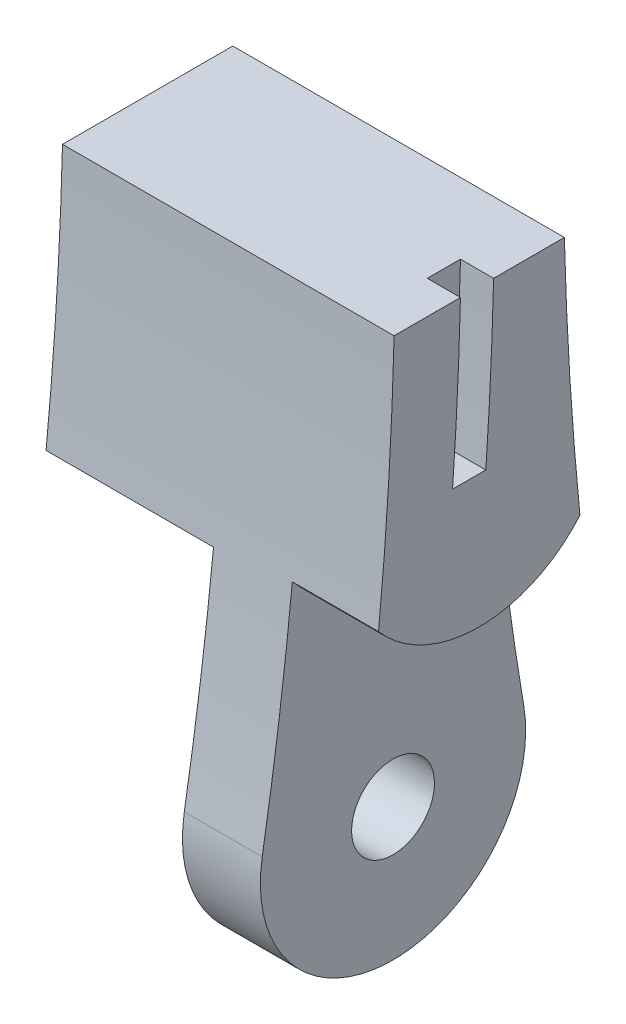
from build123d import *

# Parameters (mm, degrees)
SKETCH1_R                = 1.5
SKETCH1_R_2              = 2.5
BOSS_EXTRUDE1_DEPTH      = 20
SKETCH2_W                = 8.1
SKETCH2_H                = 20
SKETCH2_W_2              = 5.2
SKETCH2_W_3              = 5.1
CUT_EXTRUDE1_DEPTH       = 20
CUT_EXTRUDE1_DEPTH_BACK  = 20
CUT_EXTRUDE2_DEPTH       = 9
BOSS_EXTRUDE2_DEPTH      = 11.9
SKETCH5_R                = 3
BOSS_EXTRUDE3_DEPTH      = 5
CUT_EXTRUDE6_DEPTH       = 1
SKETCH13_R               = 2.5
CUT_EXTRUDE7_DEPTH       = 4
BOSS_EXTRUDE4_DEPTH      = 3
CUT_EXTRUDE9_DEPTH       = 3
SKETCH17_W               = 9
SKETCH17_H               = 3.569322199
CUT_EXTRUDE11_DEPTH      = 3
SKETCH18_W               = 5.770974844
SKETCH18_H               = 0.772936936
BOSS_EXTRUDE5_DEPTH      = 6.9
BOSS_EXTRUDE5_DEPTH_BACK = 1
SKETCH19_W               = 5.1
SKETCH19_H               = 16.397725614
CUT_EXTRUDE12_DEPTH      = 0.301495
SKETCH20_W               = 5
SKETCH20_H               = 12.419235667
CUT_EXTRUDE13_DEPTH      = 10
BOSS_EXTRUDE6_DEPTH      = 2
SKETCH23_W               = 4.9
SKETCH23_H               = 6
BOSS_EXTRUDE7_DEPTH      = 4
SKETCH22_R               = 1
CUT_EXTRUDE15_DEPTH      = 8
BOSS_EXTRUDE8_DEPTH      = 2
SKETCH14_R               = 1.5
CUT_EXTRUDE8_DEPTH       = 10.1
CUT_EXTRUDE17_DEPTH      = 8.1
CUT_EXTRUDE17_DEPTH_BACK = 2
CUT_EXTRUDE18_DEPTH      = 2
CUT_EXTRUDE20_DEPTH      = 5.2
SKETCH30_W               = 6.9
SKETCH30_H               = 20
CUT_EXTRUDE21_DEPTH      = 0.283797
CUT_EXTRUDE22_REACH      = 91.699
SKETCH31_W               = 2
SKETCH31_H               = 11.022421386
CUT_EXTRUDE23_DEPTH      = 7
CUT_EXTRUDE24_DEPTH      = 21
SKETCH34_W               = 70.65252795
SKETCH34_H               = 74.33474439
CUT_EXTRUDE25_DEPTH      = 21


with BuildPart() as part:
    # Sketch1 → Boss-Extrude1 (new body)
    with BuildSketch(Plane(origin=(0, 0, 0), x_dir=(0, 0, -1), z_dir=(1, 0, 0))):
        with BuildLine():
            ThreePointArc((9.765353557, 20.116545894), (0, 32.270117322), (-9.765353557, 20.116545894))
            ThreePointArc((-9.765353557, 20.116545894), (-5.132645827, -18.047253777), (-7.88740095, -56.392382678))
            ThreePointArc((-7.88740095, -56.392382678), (0, -65.729882678), (7.88740095, -56.392382678))
            ThreePointArc((7.88740095, -56.392382678), (5.132645827, -18.047253777), (9.765353557, 20.116545894))
        make_face()
        with Locations((0, 22.270117322)):
            Circle(SKETCH1_R, mode=Mode.SUBTRACT)
        with Locations((0, -57.729882678)):
            Circle(SKETCH1_R_2, mode=Mode.SUBTRACT)
    extrude(amount=BOSS_EXTRUDE1_DEPTH)

    # Sketch2 → Cut-Extrude1 (cut, two sides)
    with BuildSketch(Plane.XY) as cut_extrude1_sk:
        with Locations((4.05, -55.729882678)):
            Rectangle(SKETCH2_W, SKETCH2_H)
        with Locations((17.4, -55.729882678)):
            Rectangle(SKETCH2_W_2, SKETCH2_H)
        with Locations((5.55, 22.270117322)):
            Rectangle(SKETCH2_W_3, SKETCH2_H)
    extrude(amount=CUT_EXTRUDE1_DEPTH, mode=Mode.SUBTRACT)
    extrude(cut_extrude1_sk.sketch, amount=-CUT_EXTRUDE1_DEPTH_BACK, mode=Mode.SUBTRACT)

    # Sketch3 → Cut-Extrude2 (cut)
    with BuildSketch(Plane.ZY.offset(-8.1)):
        with BuildLine():
            Line((8.5, 22.270117322), (8.5, 40.909533312))
            Line((8.5, 40.909533312), (-17.52872033, 40.909533312))
            Line((-17.52872033, 40.909533312), (-17.52872033, 13.770117322))
            Line((-17.52872033, 13.770117322), (0, 13.770117322))
            ThreePointArc((0, 13.770117322), (6.01040764, 16.259709682), (8.5, 22.270117322))
        make_face()
    extrude(amount=-CUT_EXTRUDE2_DEPTH, mode=Mode.SUBTRACT)

    # Sketch4 → Boss-Extrude2 (add, through all)
    with BuildSketch(Plane.ZY.offset(-8.1)):
        Polygon((8.5, 27.537944199), (8.283796844, 12.741558936), (10.283796844, 12.741558936), (10.283796844, 27.537944199), align=None)
    extrude(amount=-BOSS_EXTRUDE2_DEPTH)

    # Sketch5 → Boss-Extrude3 (add)
    with BuildSketch(Plane.ZY.offset(-8.1)):
        with BuildLine():
            Line((8.145156861, 11.968622), (8.447845456, 23.968622))
            Line((8.447845456, 23.968622), (9.854698466, 23.968622))
            Line((9.854698466, 23.968622), (15.022421386, 23.968622))
            ThreePointArc((15.022421386, 23.968622), (21.022421386, 17.968622), (15.022421386, 11.968622))
            Line((15.022421386, 11.968622), (8.145156861, 11.968622))
        make_face()
        with Locations((15.022421386, 17.968622)):
            Circle(SKETCH5_R, mode=Mode.SUBTRACT)
    extrude(amount=-BOSS_EXTRUDE3_DEPTH)

    # Sketch12 → Cut-Extrude6 (cut)
    with BuildSketch(Plane(origin=(13.1, 0, 0), x_dir=(0, 0, -1), z_dir=(1, 0, 0))):
        Polygon((-13.902900694, 14.968622), (-13.902900694, 12.968622), (-15.902900694, 12.968622), (-15.902900694, 14.968622), (-15.902900694, 15.294296094), (-13.902900694, 15.294296094), align=None)
    extrude(amount=-CUT_EXTRUDE6_DEPTH, mode=Mode.SUBTRACT)

    # Sketch13 → Cut-Extrude7 (cut)
    with BuildSketch(Plane.ZY.offset(-17.1)):
        with Locations((0, 22.270117322)):
            Circle(SKETCH13_R)
    extrude(amount=-CUT_EXTRUDE7_DEPTH, mode=Mode.SUBTRACT)

    # Sketch15 → Boss-Extrude4 (add)
    with BuildSketch(Plane.ZY):
        Polygon((10, 22.270117322), (10, 11.968622), (8.145156861, 11.968622), (7.595672539, 11.968622), align=None)
    extrude(amount=-BOSS_EXTRUDE4_DEPTH)

    # Sketch16 → Cut-Extrude9 (cut)
    with BuildSketch(Plane(origin=(20, 0, 0), x_dir=(0, 0, -1), z_dir=(1, 0, 0))):
        with BuildLine():
            Line((-10.283796844, 23.968622), (-9.854698466, 23.968622))
            ThreePointArc((-9.854698466, 23.968622), (-9.349264901, 25.818531871), (-8.5, 27.537944199))
            Line((-8.5, 27.537944199), (-10.283796844, 27.537944199))
            Line((-10.283796844, 27.537944199), (-10.283796844, 23.968622))
        make_face()
    extrude(amount=-CUT_EXTRUDE9_DEPTH, mode=Mode.SUBTRACT)

    # Sketch17 → Cut-Extrude11 (cut)
    with BuildSketch(Plane.XY.offset(10.283796844)):
        with Locations((12.6, 25.7532831)):
            Rectangle(SKETCH17_W, SKETCH17_H)
    extrude(amount=-CUT_EXTRUDE11_DEPTH, mode=Mode.SUBTRACT)

    # Sketch18 → Boss-Extrude5 (add, two sides)
    with BuildSketch(Plane(origin=(13.1, 0, 0), x_dir=(0, 0, -1), z_dir=(1, 0, 0))) as boss_extrude5_sk:
        with Locations((-7.398309422, 12.355090468)):
            Rectangle(SKETCH18_W, SKETCH18_H)
    extrude(amount=BOSS_EXTRUDE5_DEPTH)
    extrude(boss_extrude5_sk.sketch, amount=-BOSS_EXTRUDE5_DEPTH_BACK)

    # Sketch19 → Cut-Extrude12 (cut)
    with BuildSketch(Plane(origin=(0, 12.270117322, 0), x_dir=(1, 0, 0), z_dir=(0, 1, 0))):
        with Locations((5.55, 0)):
            Rectangle(SKETCH19_W, SKETCH19_H)
    extrude(amount=-CUT_EXTRUDE12_DEPTH, mode=Mode.SUBTRACT)

    # Sketch20 → Cut-Extrude13 (cut)
    with BuildSketch(Plane.ZY.offset(-17.1)):
        with Locations((0, 28.479735156)):
            Rectangle(SKETCH20_W, SKETCH20_H)
    extrude(amount=-CUT_EXTRUDE13_DEPTH, mode=Mode.SUBTRACT)

    # Sketch21 → Boss-Extrude6 (add)
    with BuildSketch(Plane.ZY.offset(-17.1)):
        with BuildLine():
            Line((-8.473151119, 13.770117322), (0.278481736, 12.273995678))
            ThreePointArc((0.278481736, 12.273995678), (9.936881703, 21.148341047), (2.5, 31.952575688))
            Line((2.5, 31.952575688), (2.5, 22.270117322))
            ThreePointArc((2.5, 22.270117322), (0, 19.770117322), (-2.5, 22.270117322))
            Line((-2.5, 22.270117322), (-2.5, 31.952575688))
            ThreePointArc((-2.5, 31.952575688), (-8.522477621, 27.501501002), (-9.765353557, 20.116545894))
            ThreePointArc((-9.765353557, 20.116545894), (-9.093560923, 16.948562662), (-8.473151119, 13.770117322))
        make_face()
    extrude(amount=BOSS_EXTRUDE6_DEPTH)

    # Sketch23 → Boss-Extrude7 (add)
    with BuildSketch(Plane.XY.offset(10.283796844)):
        with Locations((17.55, 26.968622)):
            Rectangle(SKETCH23_W, SKETCH23_H)
    extrude(amount=-BOSS_EXTRUDE7_DEPTH)

    # Sketch22 → Cut-Extrude15 (cut)
    with BuildSketch(Plane.XY.offset(10.283796844)):
        with Locations((17.55, 26.870117322)):
            Circle(SKETCH22_R)
    extrude(amount=-CUT_EXTRUDE15_DEPTH, mode=Mode.SUBTRACT)

    # Sketch24 → Boss-Extrude8 (add)
    with BuildSketch(Plane.ZY.offset(-8.1)):
        with BuildLine():
            Line((5.147845456, 19.737443909), (5.147845456, 15.506265819))
            Line((5.147845456, 15.506265819), (8.447845456, 15.506265819))
            Line((8.447845456, 15.506265819), (8.447845456, 23.968622))
            add(Edge.make_bspline(
                [(8.447845456, 23.968622), (5.147845456, 23.968622), (5.147845456, 19.737443909)],
                knots=[3.141592654, 3.141592654, 3.141592654, 4.71238898, 4.71238898, 4.71238898], degree=2, weights=[1, 0.707106781, 1]))
        make_face()
    extrude(amount=-BOSS_EXTRUDE8_DEPTH)

    # Sketch14 → Cut-Extrude8 (cut)
    with BuildSketch(Plane.ZY):
        with Locations((7.532575614, 18.331804915)):
            Circle(SKETCH14_R)
    extrude(amount=-CUT_EXTRUDE8_DEPTH, mode=Mode.SUBTRACT)

    # Sketch25 → Cut-Extrude17 (cut, two sides)
    with BuildSketch(Plane.ZY.offset(-8.1)) as cut_extrude17_sk:
        with BuildLine():
            Line((12, -45.729882678), (8.346153846, -36.960651908))
            ThreePointArc((8.346153846, -36.960651908), (6.973852263, -42.37911752), (2.5, -45.729882678))
            Line((2.5, -45.729882678), (2.5, -53.227383372))
            ThreePointArc((2.5, -53.227383372), (0, -62.879882678), (-2.5, -53.227383372))
            Line((-2.5, -53.227383372), (-2.5, -45.729882678))
            ThreePointArc((-2.5, -45.729882678), (-6.973852263, -42.37911752), (-8.346153846, -36.960651908))
            Line((-8.346153846, -36.960651908), (-12, -45.729882678))
            Line((-12, -45.729882678), (-12, -57.729882678))
            ThreePointArc((-12, -57.729882678), (0, -69.729882678), (12, -57.729882678))
            Line((12, -57.729882678), (12, -45.729882678))
        make_face()
    extrude(amount=CUT_EXTRUDE17_DEPTH, mode=Mode.SUBTRACT)
    extrude(cut_extrude17_sk.sketch, amount=-CUT_EXTRUDE17_DEPTH_BACK, mode=Mode.SUBTRACT)

    # Sketch26 → Cut-Extrude18 (cut)
    with BuildSketch(Plane(origin=(20, 0, 0), x_dir=(0, 0, -1), z_dir=(1, 0, 0))):
        with BuildLine():
            Line((-7.209968303, 15.085404497), (-10.283796844, 15.085404497))
            Line((-10.283796844, 15.085404497), (-10.283796844, 17.085404497))
            Line((-10.283796844, 17.085404497), (-7.209968303, 17.085404497))
            ThreePointArc((-7.209968303, 17.085404497), (-4.010444351, 15.949526558), (-2.243391617, 13.050441039))
            ThreePointArc((-2.243391617, 13.050441039), (0.649659998, -12.257973546), (0.397031114, -37.729953741))
            Line((0.397031114, -37.729953741), (-1.608183929, -37.729953741))
            ThreePointArc((-1.608183929, -37.729953741), (-1.343036313, -12.450773719), (-4.206611504, 12.667092093))
            ThreePointArc((-4.206611504, 12.667092093), (-5.281990934, 14.405678614), (-7.209968303, 15.085404497))
        make_face()
    extrude(amount=-CUT_EXTRUDE18_DEPTH, mode=Mode.SUBTRACT)

    # Sketch29 → Cut-Extrude20 (cut)
    with BuildSketch(Plane(origin=(20, 0, 0), x_dir=(0, 0, -1), z_dir=(1, 0, 0))):
        with BuildLine():
            Line((8, -37.729882678), (8.140336581, -37.729882678))
            Line((8.140336581, -37.729882678), (8.140336581, -45.937498976))
            Line((8.140336581, -45.937498976), (-15.754893946, -45.937498976))
            Line((-15.754893946, -45.937498976), (-15.754893946, -37.729882678))
            Line((-15.754893946, -37.729882678), (-8, -37.729882678))
            ThreePointArc((-8, -37.729882678), (0, -45.729882678), (8, -37.729882678))
        make_face()
    extrude(amount=-CUT_EXTRUDE20_DEPTH, mode=Mode.SUBTRACT)

    # Sketch30 → Cut-Extrude21 (cut)
    with BuildSketch(Plane.XY.offset(10.283796844)):
        with Locations((16.55, 21.968622)):
            Rectangle(SKETCH30_W, SKETCH30_H)
    extrude(amount=-CUT_EXTRUDE21_DEPTH, mode=Mode.SUBTRACT)

    # Sketch31 → Cut-Extrude22 (cut, up to next)
    with BuildSketch(Plane(origin=(0, 23.968622, 0), x_dir=(1, 0, 0), z_dir=(0, 1, 0)), mode=Mode.PRIVATE) as cut_extrude22_sk1:
        with Locations((9.1, -15.511210693)):
            Rectangle(SKETCH31_W, SKETCH31_H)
    cut_extrude22_tool1 = extrude(cut_extrude22_sk1.sketch, amount=-CUT_EXTRUDE22_REACH, mode=Mode.PRIVATE) & part.part
    add(cut_extrude22_tool1.solids().sort_by_distance((9.1, 23.968622, 15.511211))[0], mode=Mode.SUBTRACT)

    # Sketch32 → Cut-Extrude23 (cut)
    with BuildSketch(Plane.ZY.offset(-8.1)):
        Polygon((-8.473151119, 13.770117322), (-8.473151119, 5.401068454), (5.147845456, 15.506265819), align=None)
    extrude(amount=-CUT_EXTRUDE23_DEPTH, mode=Mode.SUBTRACT)

    # Sketch33 → Cut-Extrude24 (cut, through all)
    with BuildSketch(Plane(origin=(20, 0, 0), x_dir=(0, 0, -1), z_dir=(1, 0, 0))):
        Polygon((-9.30475326, -22.954882678), (-9.30475326, -27.954882678), (8.892389241, -27.954882678), (8.892389241, -22.954882678), (8.892389241, -17.954882678), (-9.30475326, -17.954882678), align=None)
    extrude(amount=-CUT_EXTRUDE24_DEPTH, mode=Mode.SUBTRACT)

    # Sketch34 → Cut-Extrude25 (cut, through all)
    with BuildSketch(Plane(origin=(20, 0, 0), x_dir=(0, 0, -1), z_dir=(1, 0, 0))):
        with Locations((-4.594652679, 17.444902541)):
            Rectangle(SKETCH34_W, SKETCH34_H)
    extrude(amount=-CUT_EXTRUDE25_DEPTH, mode=Mode.SUBTRACT)


solid = part.part
